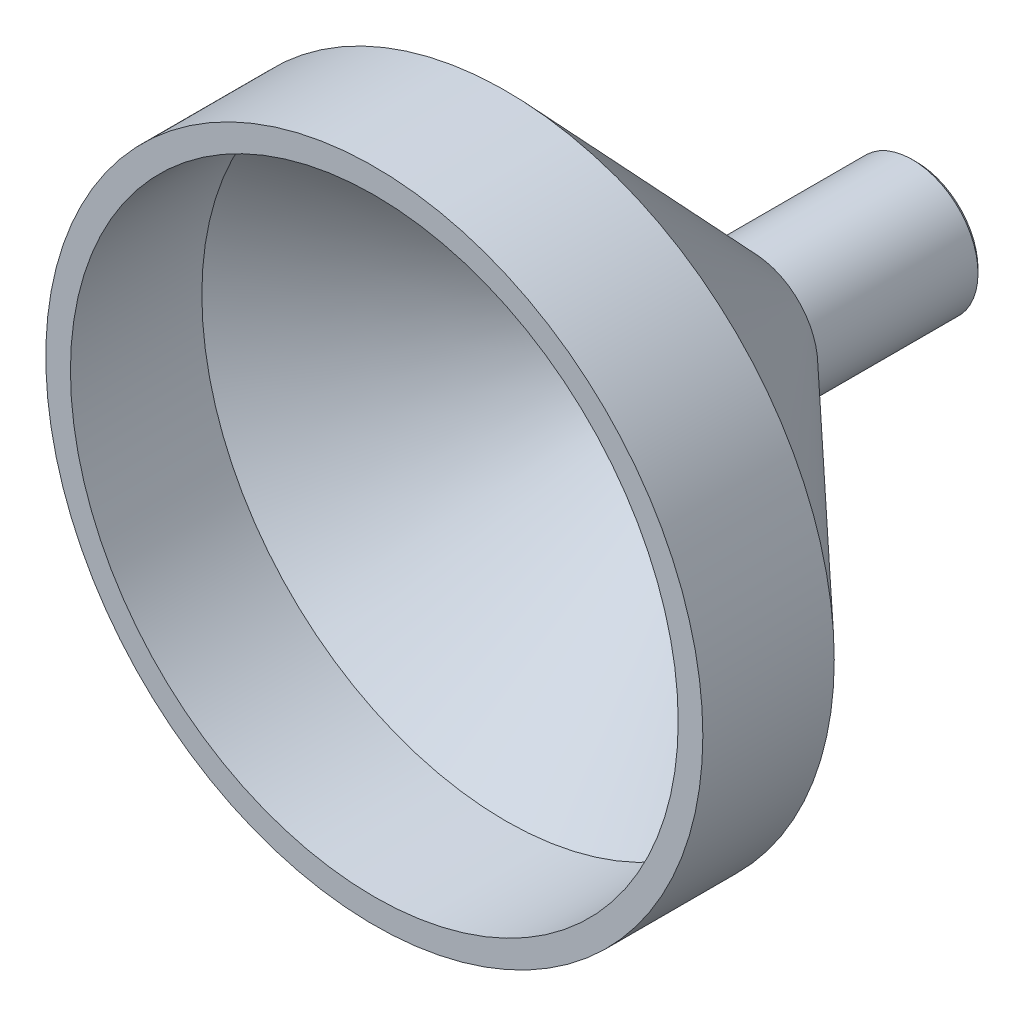
from build123d import *

# Parameters (mm, degrees)
CHAMFER2_SIZE = 0.25


with BuildPart() as part:
    # Sketch1 → Revolve1 (revolve)
    with BuildSketch(Plane(origin=(0, 0, 0), x_dir=(1, 0, 0), z_dir=(0, 1, 0))):
        Polygon((-4, 25), (-4, 15), (-20, 0), (-20, -8), (-18.5, -8), (-18.5, 0), (-3.25, 14.296875), (-3.25, 25), align=None)
    revolve(axis=Axis((0, 0, 0), (0, 0, -1)))

    # Chamfer2
    chamfer2_edges = [part.edges().sort_by_distance(p)[0] for p in [
        (4, 0, -25),
    ]]
    chamfer(chamfer2_edges, length=CHAMFER2_SIZE)


solid = part.part
